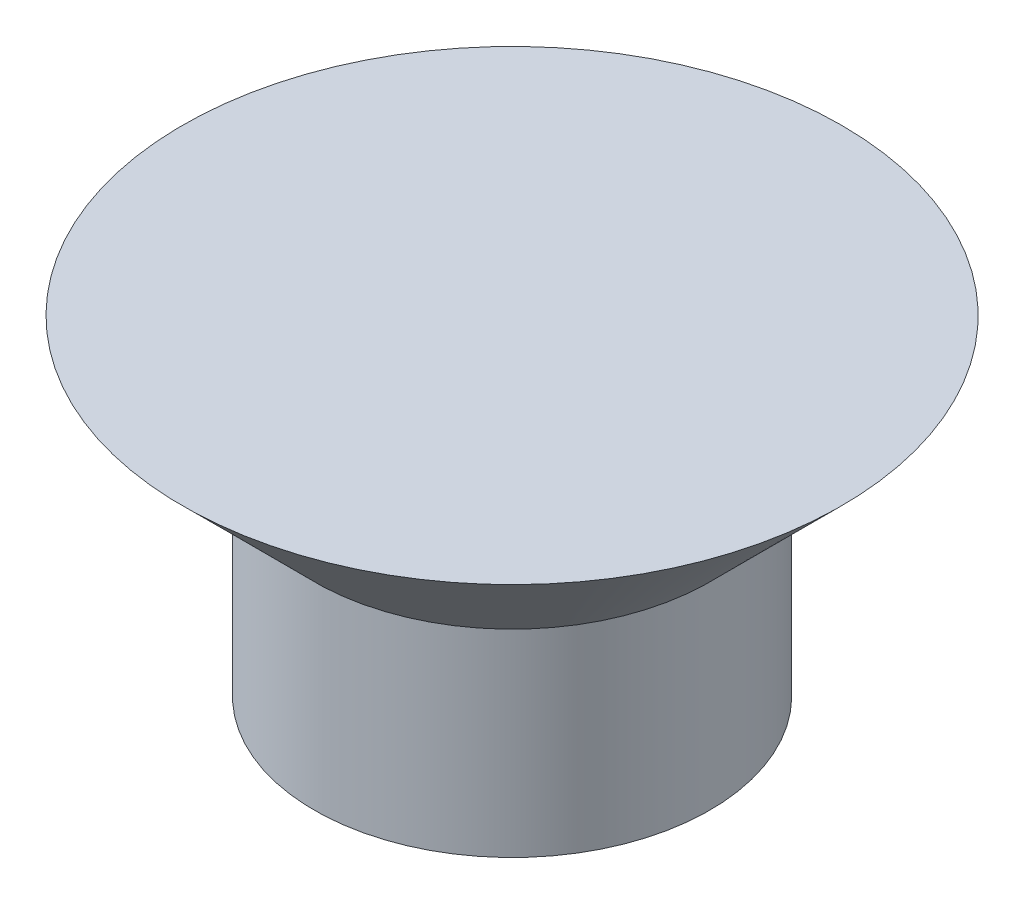
from build123d import *


with BuildPart() as part:
    # Sketch1 → Revolve1 (revolve)
    with BuildSketch(Plane.XY):
        Polygon((0, 0), (0, 2.5), (2.5, 2.5), (1.5, 1.5), (1.5, 0), align=None)
    revolve(axis=Axis((0, 0, 0), (0, 1, 0)))


solid = part.part
